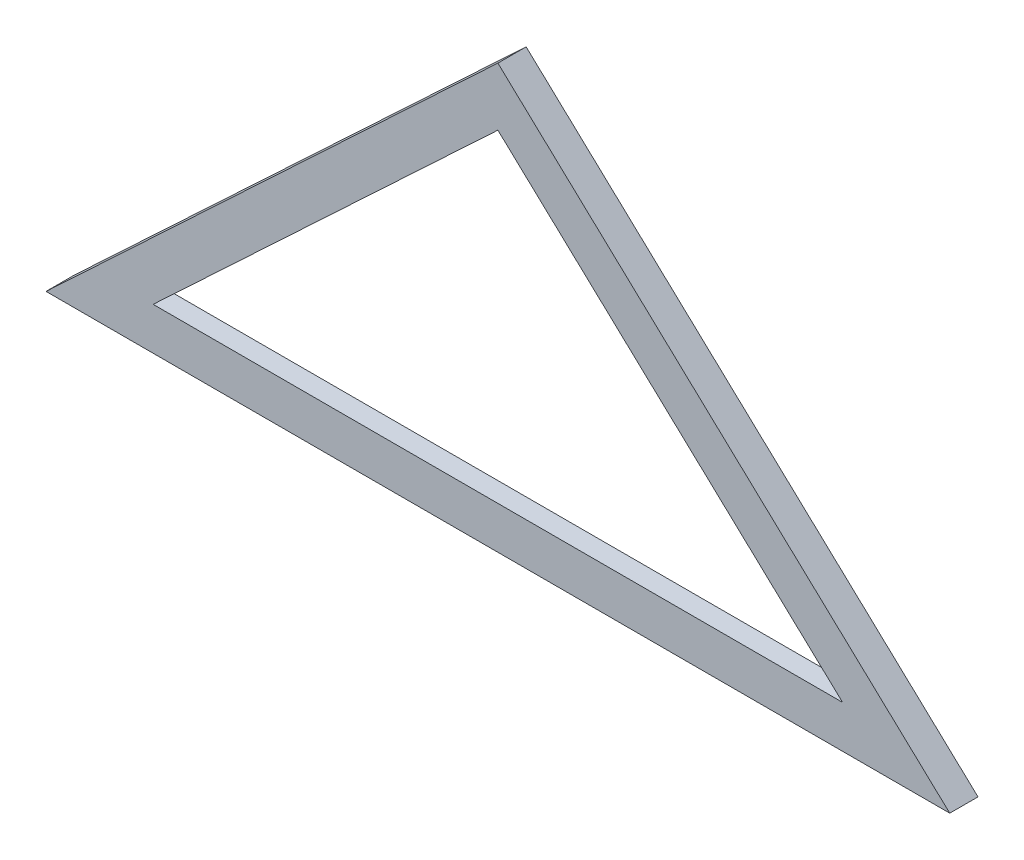
from build123d import *

# Parameters (mm, degrees)
SALIENTE_EXTRUIR1_DEPTH = 10
CORTAR_EXTRUIR1_DEPTH   = 3


with BuildPart() as part:
    # Croquis1 → Saliente-Extruir1 (new body)
    with BuildSketch(Plane.XY):
        Polygon((0, 0), (320, 0), (160, 150), align=None)
        Polygon((160, 129.439019813), (282.068287801, 15), (37.931712199, 15), align=None, mode=Mode.SUBTRACT)
    extrude(amount=SALIENTE_EXTRUIR1_DEPTH)

    # Croquis2 → Cortar-Extruir1 (cut)
    with BuildSketch(Plane(origin=(0, 0, 0), x_dir=(-1, 0, 0), z_dir=(0, 0, -1))):
        Polygon((-294.712191867, 10), (-25.287808133, 10), (-160, 136.292679875), align=None)
    extrude(amount=-CORTAR_EXTRUIR1_DEPTH, mode=Mode.SUBTRACT)


solid = part.part
